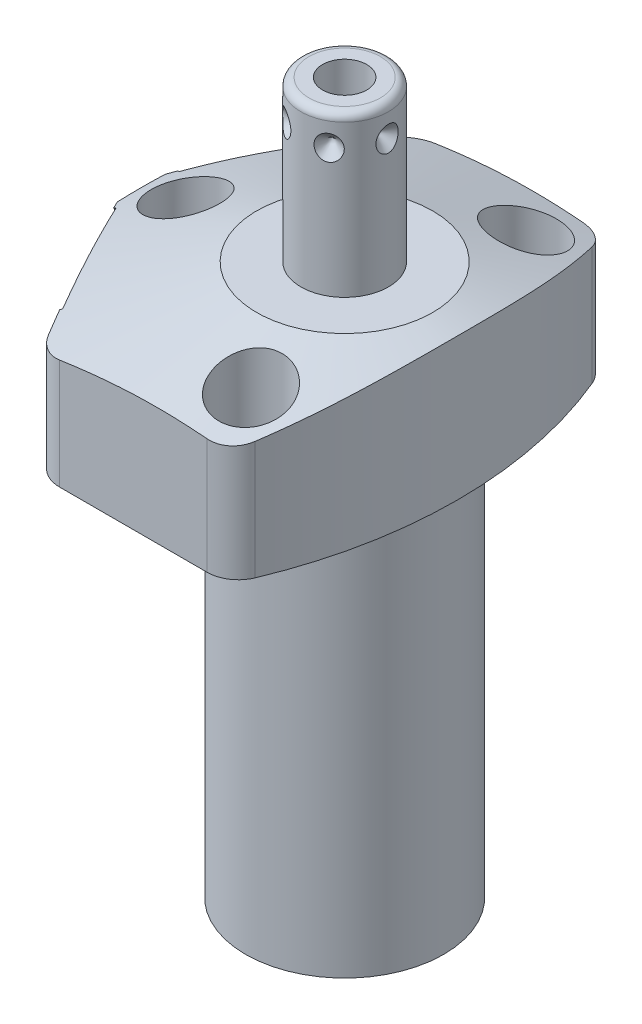
from build123d import *

# Parameters (mm, degrees)
CUT_EXTRUDE1_REACH = 21.05
CUT_EXTRUDE2_REACH = 21.05
S2D0002_OUTSIDE_W  = 78.27
S2D0002_OUTSIDE_H  = 69.906
CUT_EXTRUDE3_DEPTH = 26.035
FILLET1_R          = 3.9624
SKETCH17_R         = 10.4775
CUT_EXTRUDE4_DEPTH = 0.254
SKETCH18_R         = 10.4775
CUT_EXTRUDE5_DEPTH = 0.254
SKETCH19_R         = 5.5626
CUT_EXTRUDE6_DEPTH = 2.667
CIRPATTERN1_COUNT  = 6
HOLE1_D            = 5.5626
HOLE1_DEPTH        = 19.05
HOLE1_CBORE_D      = 8.7122
HOLE1_CBORE_DEPTH  = 11.0998


with BuildPart() as part:
    # Sketch1 → Revolve1 (revolve)
    with BuildSketch(Plane(origin=(0, 0, 0), x_dir=(0, -1, 0), z_dir=(0, 0, 1)), mode=Mode.PRIVATE) as revolve1_sk:
        Polygon((0, 28.575), (-19.05, 28.575), (-19.05, 0), (50.8, 0), (50.8, 12.573), (0, 12.573), align=None)
    revolve(revolve1_sk.sketch.rotate(Axis((0, 22.5425, 0), (0, -1, 0)), 90), axis=Axis((0, 22.5425, 0), (0, -1, 0)))  # turned: the seam where the file's is

    # Sketch2 → Cut-Extrude1 (cut, up to next)
    with BuildSketch(Plane(origin=(0, 0, 0), x_dir=(0, 0, -1), z_dir=(0, -1, 0)), mode=Mode.PRIVATE) as cut_extrude1_sk1:
        with BuildLine():
            Line((23.8125, -15.795425564), (23.8125, 15.795425564))
            ThreePointArc((23.8125, 15.795425564), (28.575, 0), (23.8125, -15.795425564))
        make_face()
    cut_extrude1_tool1 = extrude(cut_extrude1_sk1.sketch, amount=-CUT_EXTRUDE1_REACH, mode=Mode.PRIVATE) & part.part
    add(cut_extrude1_tool1.solids().sort_by_distance((0, 0, -25.731798))[0], mode=Mode.SUBTRACT)
    # Sketch2 → Cut-Extrude1 (cut, up to next)
    with BuildSketch(Plane(origin=(0, 0, 0), x_dir=(0, 0, -1), z_dir=(0, -1, 0)), mode=Mode.PRIVATE) as cut_extrude1_sk2:
        with BuildLine():
            Line((-23.8125, 15.795425564), (-23.8125, -15.795425564))
            ThreePointArc((-23.8125, -15.795425564), (-28.575, 0), (-23.8125, 15.795425564))
        make_face()
    cut_extrude1_tool2 = extrude(cut_extrude1_sk2.sketch, amount=-CUT_EXTRUDE1_REACH, mode=Mode.PRIVATE) & part.part
    add(cut_extrude1_tool2.solids().sort_by_distance((0, 0, 25.731798))[0], mode=Mode.SUBTRACT)

    # Sketch3 → Cut-Extrude2 (cut, up to next)
    with BuildSketch(Plane(origin=(0, 0, 0), x_dir=(-1, 0, 0), z_dir=(0, -1, 0)), mode=Mode.PRIVATE) as cut_extrude2_sk1:
        with BuildLine():
            Line((14.75388632, 23.8125), (27.415217161, 0))
            Line((27.415217161, 0), (14.75388632, -23.8125))
            Line((14.75388632, -23.8125), (15.795425564, -23.8125))
            ThreePointArc((15.795425564, -23.8125), (28.575, 0), (15.795425564, 23.8125))
            Line((15.795425564, 23.8125), (14.75388632, 23.8125))
        make_face()
    cut_extrude2_tool1 = extrude(cut_extrude2_sk1.sketch, amount=-CUT_EXTRUDE2_REACH, mode=Mode.PRIVATE) & part.part
    add(cut_extrude2_tool1.solids().sort_by_distance((-15.274656, 0, -23.3166))[0], mode=Mode.SUBTRACT)

    # S2D0002 outside → Cut-Extrude3 (cut)
    with BuildSketch(Plane(origin=(0, 0, 0), x_dir=(-1, 0, 0), z_dir=(0, -1, 0))):
        with Locations((-0.58, 0)):
            Rectangle(S2D0002_OUTSIDE_W, S2D0002_OUTSIDE_H)
        with BuildLine():
            Line((25.8064, 53.379071452), (25.8064, -53.379071452))
            ThreePointArc((25.8064, -53.379071452), (-14.3002, 0), (25.8064, 53.379071452))
        make_face(mode=Mode.SUBTRACT)
    extrude(amount=-CUT_EXTRUDE3_DEPTH, mode=Mode.SUBTRACT)

    # Fillet1
    fillet1_edges = [part.edges().sort_by_distance(p)[0] for p in [
        (-14.75388632, 9.525, 23.8125),
        (-14.75388632, 9.525, -23.8125),
        (8.940213818, 9.525, 23.8125),
        (8.940213818, 9.525, -23.8125),
    ]]
    fillet(fillet1_edges, radius=FILLET1_R)

    # Sketch5 → Cut-Revolve1 (revolve, cut)
    with BuildSketch(Plane.XY, mode=Mode.PRIVATE) as cut_revolve1_sk:
        Polygon((-11.176, 19.05), (-44.45, 8.238622028), (-44.45, 19.05), align=None)
    revolve(cut_revolve1_sk.sketch.rotate(Axis((0, 5.998428823, 0), (0, 1, 0)), 90), axis=Axis((0, 5.998428823, 0), (0, 1, 0)), mode=Mode.SUBTRACT)  # turned: the seam where the file's is

    # Sketch6 → Cut-Revolve2 (revolve, cut)
    with BuildSketch(Plane(origin=(-21.148537334, 7.9502, -11.244876766), x_dir=(0.469471563, 0, -0.882947593), z_dir=(0, 1, 0))):
        Polygon((0, 0), (4.5466, 0), (4.106586662, -2.0701), (3.4544, -2.722286662), (3.4544, -12.192), (0, -12.192), align=None)
    revolve(axis=Axis((-9.845395429, 7.9502, -5.234889608), (-0.882947593, 0, -0.469471563)), mode=Mode.SUBTRACT)

    # Sketch7 → Cut-Revolve3 (revolve, cut)
    with BuildSketch(Plane(origin=(-21.148537334, 7.9502, 11.244876766), x_dir=(-0.469471563, 0, -0.882947593), z_dir=(0, 1, 0))):
        Polygon((0, 0), (4.5466, 0), (4.106586662, -2.0701), (3.4544, -2.722286662), (3.4544, -12.192), (0, -12.192), align=None)
    revolve(axis=Axis((-9.845395429, 7.9502, 5.234889608), (-0.882947593, 0, 0.469471563)), mode=Mode.SUBTRACT)

    # Sketch17 → Cut-Extrude4 (cut)
    with BuildSketch(Plane(origin=(-21.372806022, 0, 11.364122543), x_dir=(0.469471563, 0, 0.882947593), z_dir=(-0.882947593, 0, 0.469471563))):
        with Locations((0, 7.9502)):
            Circle(SKETCH17_R)
    extrude(amount=-CUT_EXTRUDE4_DEPTH, mode=Mode.SUBTRACT)

    # Sketch18 → Cut-Extrude5 (cut)
    with BuildSketch(Plane(origin=(-21.372806022, 0, -11.364122543), x_dir=(-0.469471563, 0, 0.882947593), z_dir=(-0.882947593, 0, -0.469471563))):
        with Locations((0, 7.9502)):
            Circle(SKETCH18_R)
    extrude(amount=-CUT_EXTRUDE5_DEPTH, mode=Mode.SUBTRACT)

    # Sketch8 → Cut-Revolve4 (revolve, cut)
    with BuildSketch(Plane(origin=(-11.1252, 2.667, -15.875), x_dir=(-1, 0, 0), z_dir=(0, 0, 1)), mode=Mode.PRIVATE) as cut_revolve4_sk:
        Polygon((0, 0), (4.5466, 0), (4.106586662, -2.0701), (3.4544, -2.722286662), (3.4544, -11.684), (0, -11.684), align=None)
    revolve(cut_revolve4_sk.sketch.rotate(Axis((-11.1252, 14.9352, -15.875), (0, -1, 0)), 270), axis=Axis((-11.1252, 14.9352, -15.875), (0, -1, 0)), mode=Mode.SUBTRACT)  # turned: the seam where the file's is

    # Sketch9 → Cut-Revolve5 (revolve, cut)
    with BuildSketch(Plane(origin=(-11.1252, 2.667, 15.875), x_dir=(-1, 0, 0), z_dir=(0, 0, 1)), mode=Mode.PRIVATE) as cut_revolve5_sk:
        Polygon((0, 0), (4.5466, 0), (4.106586662, -2.0701), (3.4544, -2.722286662), (3.4544, -11.684), (0, -11.684), align=None)
    revolve(cut_revolve5_sk.sketch.rotate(Axis((-11.1252, 14.9352, 15.875), (0, -1, 0)), 270), axis=Axis((-11.1252, 14.9352, 15.875), (0, -1, 0)), mode=Mode.SUBTRACT)  # turned: the seam where the file's is

    # Sketch10 → Revolve2 (revolve)
    with BuildSketch(Plane(origin=(0, 0, 0), x_dir=(0, 0, -1), z_dir=(1, 0, 0)), mode=Mode.PRIVATE) as revolve2_sk:
        with BuildLine():
            Line((0, 19.05), (-5.55625, 19.05))
            Line((-5.55625, 19.05), (-5.55625, 38.3032))
            ThreePointArc((-5.55625, 38.3032), (-5.25867049, 39.02162049), (-4.54025, 39.3192))
            Line((-4.54025, 39.3192), (0, 39.3192))
            Line((0, 39.3192), (0, 19.05))
        make_face()
    revolve(revolve2_sk.sketch.rotate(Axis((0, 18.03654, 0), (0, 1, 0)), 180), axis=Axis((0, 18.03654, 0), (0, 1, 0)))  # turned: the seam where the file's is

    # Sketch19 → Cut-Extrude6 (cut)
    with BuildSketch(Plane.XZ):
        with Locations(Location((-11.1252, -15.875, 0), (0, 0, 270))):  # turned: the seam where the file's is
            Circle(SKETCH19_R)
        with Locations(Location((-11.1252, 15.875, 0), (0, 0, 270))):  # turned: the seam where the file's is
            Circle(SKETCH19_R)
    extrude(amount=-CUT_EXTRUDE6_DEPTH, mode=Mode.SUBTRACT)

    # S2D0001 → Cut-Revolve6 (revolve, cut)
    with BuildSketch(Plane(origin=(2.8067, 39.3192, 0), x_dir=(1, 0, 0), z_dir=(0, 0, 1)), mode=Mode.PRIVATE) as cut_revolve6_sk:
        Polygon((0, 0), (0, -10.16), (-2.8067, -11.846435499), (-2.8067, 0), align=None)
    revolve(cut_revolve6_sk.sketch.rotate(Axis((0, 21.752471385, 0), (0, 1, 0)), 90), axis=Axis((0, 21.752471385, 0), (0, 1, 0)), mode=Mode.SUBTRACT)  # turned: the seam where the file's is

    # Sketch14 → Revolve3 (revolve)
    with BuildSketch(Plane(origin=(-11.1252, 0, 15.875), x_dir=(0, 0, -1), z_dir=(1, 0, 0))):
        with BuildLine():
            Line((5.461, 2.667), (5.461, 0.9398))
            Line((5.461, 0.9398), (5.301559456, 0.9398))
            ThreePointArc((5.301559456, 0.9398), (4.572, -0.4572), (3.842440544, 0.9398))
            Line((3.842440544, 0.9398), (3.175, 0.9398))
            ThreePointArc((3.175, 0.9398), (2.815789755, 0.791010245), (2.667, 0.4318))
            Line((2.667, 0.4318), (2.667, 0.127))
            Line((2.667, 0.127), (1.5875, 0.127))
            Line((1.5875, 0.127), (1.5875, 10.6172))
            Line((1.5875, 10.6172), (3.2512, 10.6172))
            Line((3.2512, 10.6172), (3.2512, 2.667))
            Line((3.2512, 2.667), (5.461, 2.667))
        make_face()
    revolve3 = revolve(axis=Axis((-11.1252, -1.01092, 15.875), (0, 1, 0)))

    # Sketch15 → Cut-Revolve7 (revolve, cut)
    with BuildSketch(Plane(origin=(-5.55625, 35.3568, 0), x_dir=(0, 1, 0), z_dir=(0, 0, 1)), mode=Mode.PRIVATE) as cut_revolve7_sk:
        Polygon((0, 0), (1.5875, 0), (0, -1.5875), align=None)
    cut_revolve7 = revolve(cut_revolve7_sk.sketch.rotate(Axis((-1.854476352, 35.3568, 0), (-1, 0, 0)), 270), axis=Axis((-1.854476352, 35.3568, 0), (-1, 0, 0)), mode=Mode.SUBTRACT)  # turned: the seam where the file's is

    # CirPattern1: Cut-Revolve7 ×6 about axis
    cirpattern1_axis = Axis((0, 18.03654, 0), (0, -1, 0))
    for i in range(1, CIRPATTERN1_COUNT):
        add(cut_revolve7.rotate(cirpattern1_axis, i * 360 / CIRPATTERN1_COUNT), mode=Mode.SUBTRACT)

    # Hole1
    with Locations(Plane(origin=(0, 19.05, 0), x_dir=(-1, 0, 0), z_dir=(0, 1, 0))):
        with Locations((-5.5626, -17.4498), (20.193, 0), (-5.5626, 17.4498)):
            CounterBoreHole(HOLE1_D / 2, HOLE1_CBORE_D / 2, HOLE1_CBORE_DEPTH, depth=HOLE1_DEPTH)

    # Mirror1: Revolve3 across plane
    add(revolve3.mirror(Plane.XY))


solid = part.part
